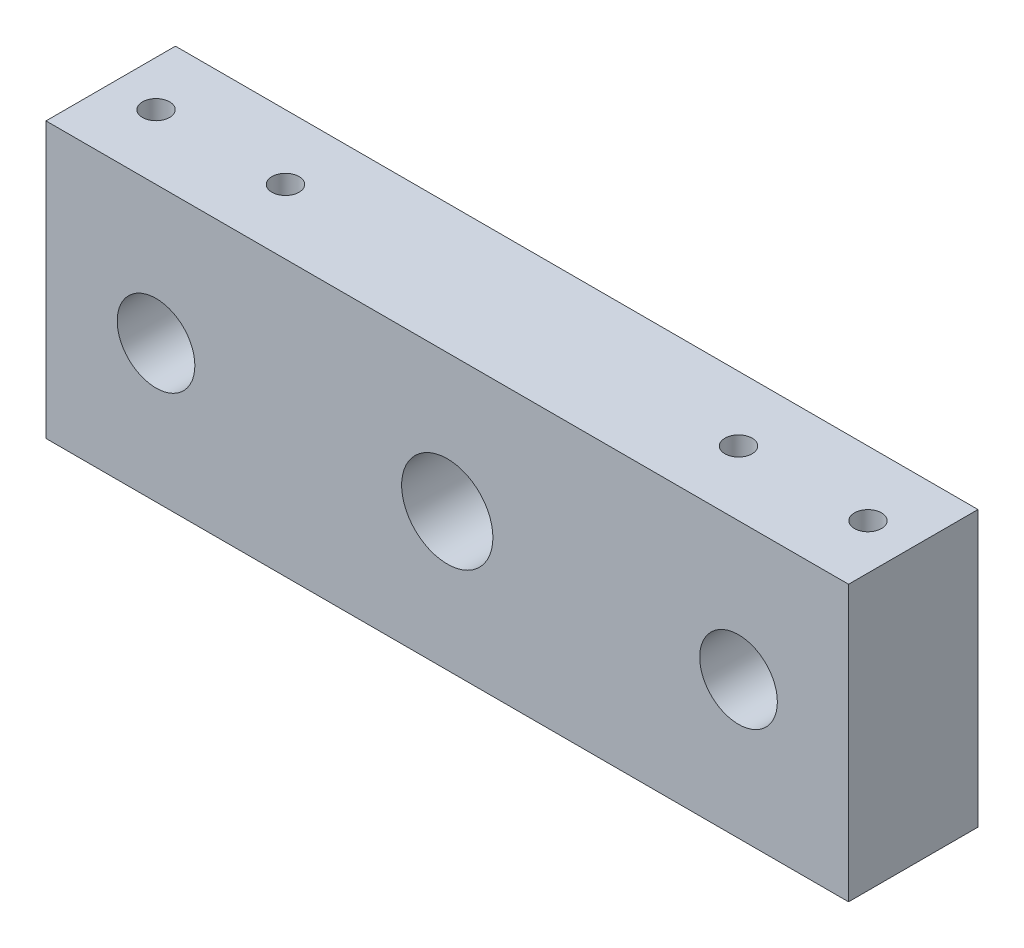
from build123d import *

# Parameters (mm, degrees)
SKETCH1_W           = 124
SKETCH1_H           = 42.5
SKETCH1_R           = 6
SKETCH1_R_2         = 5
BOSS_EXTRUDE1_DEPTH = 20
CUT_EXTRUDE1_REACH  = 44.5
SKETCH2_R           = 2.1
SKETCH3_R           = 7.05
CUT_EXTRUDE2_DEPTH  = 16


with BuildPart() as part:
    # Sketch1 → Boss-Extrude1 (new body)
    with BuildSketch(Plane.XY):
        with Locations((62, 21.25)):
            Rectangle(SKETCH1_W, SKETCH1_H)
        with Locations((17, 21.25)):
            Circle(SKETCH1_R, mode=Mode.SUBTRACT)
        with Locations((107, 21.25)):
            Circle(SKETCH1_R, mode=Mode.SUBTRACT)
        with Locations((62, 21.25)):
            Circle(SKETCH1_R_2, mode=Mode.SUBTRACT)
    extrude(amount=BOSS_EXTRUDE1_DEPTH)

    # Sketch2 → Cut-Extrude1 (cut, up to next)
    with BuildSketch(Plane.XZ, mode=Mode.PRIVATE) as cut_extrude1_sk1:
        with Locations((7, 10)):
            Circle(SKETCH2_R)
    cut_extrude1_tool1 = extrude(cut_extrude1_sk1.sketch, amount=-CUT_EXTRUDE1_REACH, mode=Mode.PRIVATE) & part.part
    add(cut_extrude1_tool1.solids().sort_by_distance((7, 0, 10))[0], mode=Mode.SUBTRACT)
    # Sketch2 → Cut-Extrude1 (cut, up to next)
    with BuildSketch(Plane.XZ, mode=Mode.PRIVATE) as cut_extrude1_sk2:
        with Locations((27, 10)):
            Circle(SKETCH2_R)
    cut_extrude1_tool2 = extrude(cut_extrude1_sk2.sketch, amount=-CUT_EXTRUDE1_REACH, mode=Mode.PRIVATE) & part.part
    add(cut_extrude1_tool2.solids().sort_by_distance((27, 0, 10))[0], mode=Mode.SUBTRACT)
    # Sketch2 → Cut-Extrude1 (cut, up to next)
    with BuildSketch(Plane.XZ, mode=Mode.PRIVATE) as cut_extrude1_sk3:
        with Locations((97, 10)):
            Circle(SKETCH2_R)
    cut_extrude1_tool3 = extrude(cut_extrude1_sk3.sketch, amount=-CUT_EXTRUDE1_REACH, mode=Mode.PRIVATE) & part.part
    add(cut_extrude1_tool3.solids().sort_by_distance((97, 0, 10))[0], mode=Mode.SUBTRACT)
    # Sketch2 → Cut-Extrude1 (cut, up to next)
    with BuildSketch(Plane.XZ, mode=Mode.PRIVATE) as cut_extrude1_sk4:
        with Locations((117, 10)):
            Circle(SKETCH2_R)
    cut_extrude1_tool4 = extrude(cut_extrude1_sk4.sketch, amount=-CUT_EXTRUDE1_REACH, mode=Mode.PRIVATE) & part.part
    add(cut_extrude1_tool4.solids().sort_by_distance((117, 0, 10))[0], mode=Mode.SUBTRACT)
    # Sketch2 → Cut-Extrude1 (cut, up to next)
    with BuildSketch(Plane.XZ, mode=Mode.PRIVATE) as cut_extrude1_sk5:
        with Locations((17, 10)):
            Circle(SKETCH2_R)
    cut_extrude1_tool5 = extrude(cut_extrude1_sk5.sketch, amount=-CUT_EXTRUDE1_REACH, mode=Mode.PRIVATE) & part.part
    add(cut_extrude1_tool5.solids().sort_by_distance((17, 0, 10))[0], mode=Mode.SUBTRACT)
    # Sketch2 → Cut-Extrude1 (cut, up to next)
    with BuildSketch(Plane.XZ, mode=Mode.PRIVATE) as cut_extrude1_sk6:
        with Locations((107, 10)):
            Circle(SKETCH2_R)
    cut_extrude1_tool6 = extrude(cut_extrude1_sk6.sketch, amount=-CUT_EXTRUDE1_REACH, mode=Mode.PRIVATE) & part.part
    add(cut_extrude1_tool6.solids().sort_by_distance((107, 0, 10))[0], mode=Mode.SUBTRACT)

    # Sketch3 → Cut-Extrude2 (cut)
    with BuildSketch(Plane.XY.offset(20)):
        with Locations((62, 21.25)):
            Circle(SKETCH3_R)
    extrude(amount=-CUT_EXTRUDE2_DEPTH, mode=Mode.SUBTRACT)


solid = part.part
